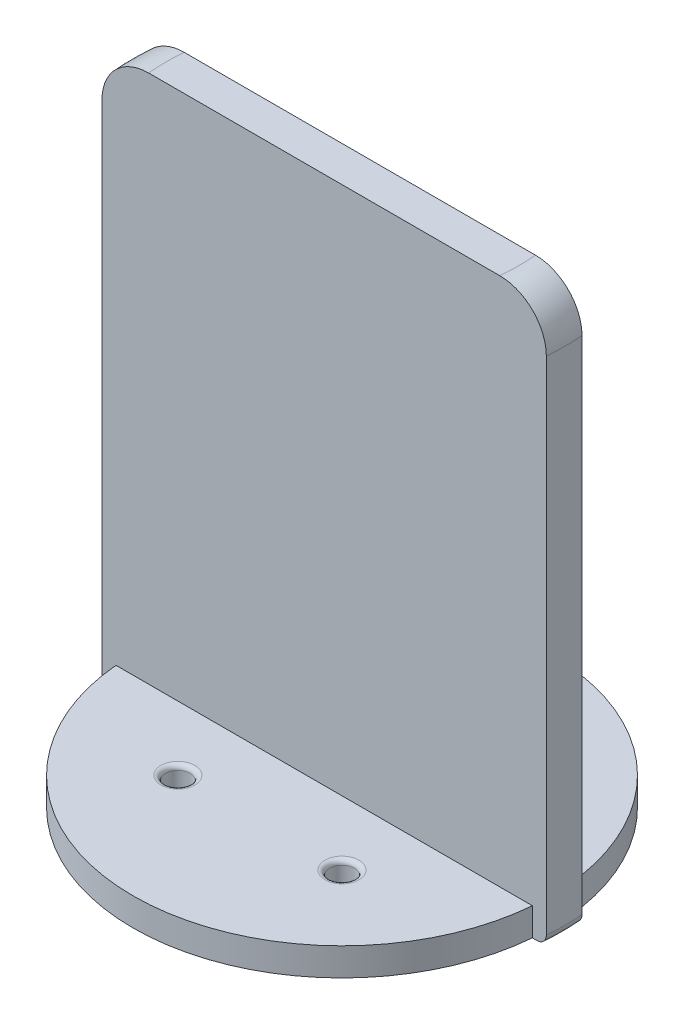
from build123d import *

# Parameters (mm, degrees)
SKETCH_1_R      = 22.5
SKETCH_1_R_2    = 1.333333333
EXTRUDE_1_DEPTH = 3
EXTRUDE_2_DEPTH = 60
FILLET_1_R      = 0.5
FILLET_2_R      = 1
FILLET_3_R      = 5


with BuildPart() as part:
    # 草图1 → 凸台-拉伸1 (new body)
    with BuildSketch(Plane(origin=(0, 0, 0), x_dir=(1, 0, 0), z_dir=(0, 1, 0))):
        Circle(SKETCH_1_R)
        with Locations((8.838834765, 8.838834765)):
            Circle(SKETCH_1_R_2, mode=Mode.SUBTRACT)
        with Locations((8.838834765, -8.838834765)):
            Circle(SKETCH_1_R_2, mode=Mode.SUBTRACT)
        with Locations((-8.838834765, -8.838834765)):
            Circle(SKETCH_1_R_2, mode=Mode.SUBTRACT)
        with Locations((-8.838834765, 8.838834765)):
            Circle(SKETCH_1_R_2, mode=Mode.SUBTRACT)
    extrude(amount=EXTRUDE_1_DEPTH)

    # 草图3 → 凸台-拉伸2 (add)
    with BuildSketch(Plane.XZ):
        with BuildLine():
            Line((-23.923076725, 1.92), (23.923076725, 1.92))
            ThreePointArc((23.923076725, 1.92), (24, 0), (23.923076725, -1.92))
            Line((23.923076725, -1.92), (-23.923076725, -1.92))
            ThreePointArc((-23.923076725, -1.92), (-24, 0), (-23.923076725, 1.92))
        make_face()
    extrude(amount=-EXTRUDE_2_DEPTH)

    # 圆角1
    fillet_1_edges = [part.edges().sort_by_distance(p)[0] for p in [
        (-10.172168098, 3, 8.838834765),
        (-10.172168098, 3, -8.838834765),
        (7.505501431, 3, -8.838834765),
        (7.505501431, 3, 8.838834765),
    ]]
    fillet(fillet_1_edges, radius=FILLET_1_R)

    # 圆角2
    fillet_2_edges = [part.edges().sort_by_distance(p)[0] for p in [
        (24, 0, 0),
        (-24, 0, 0),
    ]]
    fillet(fillet_2_edges, radius=FILLET_2_R)

    # 圆角3
    fillet_3_edges = [part.edges().sort_by_distance(p)[0] for p in [
        (-24, 60, 0),
        (24, 60, 0),
    ]]
    fillet(fillet_3_edges, radius=FILLET_3_R)


solid = part.part
